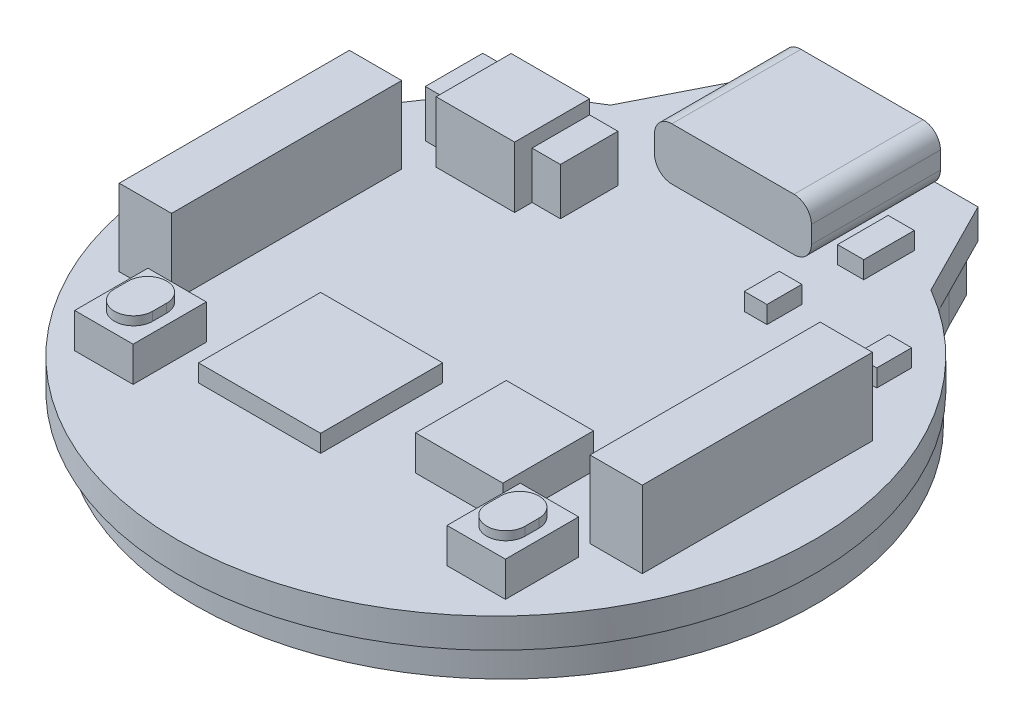
from build123d import *

# Parameters (mm, degrees)
BOSS_EXTRUDE1_DEPTH  = 1.7
BOSS_EXTRUDE2_DEPTH  = 2
BOSS_EXTRUDE3_START  = 1.7
SKETCH3_W            = 3
SKETCH3_H            = 13.2
BOSS_EXTRUDE3_DEPTH  = 4.4
BOSS_EXTRUDE4_START  = -21
BOSS_EXTRUDE4_DEPTH  = 7.4
CUT_EXTRUDE1_START   = -21
CUT_EXTRUDE1_DEPTH   = 6
BOSS_EXTRUDE5_START  = -15
SKETCH8_W            = 6
SKETCH8_H            = 0.65
BOSS_EXTRUDE5_DEPTH  = 5
FILLET1_R            = 0.5
BOSS_EXTRUDE6_START  = 1.7
SKETCH9_W            = 5
SKETCH9_H            = 5.2
BOSS_EXTRUDE6_DEPTH  = 2
BOSS_EXTRUDE7_START  = 1.7
SKETCH10_W           = 3.35
SKETCH10_H           = 4.2
BOSS_EXTRUDE7_DEPTH  = 2
BOSS_EXTRUDE8_START  = 3.7
BOSS_EXTRUDE8_DEPTH  = 0.5
BOSS_EXTRUDE9_START  = 1.7
SKETCH12_W           = 4.5
SKETCH12_H           = 4.3
BOSS_EXTRUDE9_DEPTH  = 3.5
BOSS_EXTRUDE10_START = 1.7
SKETCH13_W           = 7.75
SKETCH13_H           = 3.3
BOSS_EXTRUDE10_DEPTH = 2.7
BOSS_EXTRUDE11_START = 1.7
SKETCH14_W           = 7
SKETCH14_H           = 7
BOSS_EXTRUDE11_DEPTH = 1
BOSS_EXTRUDE12_START = 1.7
SKETCH15_W           = 1.3
SKETCH15_H           = 2
BOSS_EXTRUDE12_DEPTH = 1
BOSS_EXTRUDE13_START = 1.7
SKETCH16_W           = 1.5
SKETCH16_H           = 2.9
BOSS_EXTRUDE13_DEPTH = 1


with BuildPart() as part:
    # Sketch1 → Boss-Extrude1 (new body)
    with BuildSketch(Plane(origin=(0, 0, 0), x_dir=(1, 0, 0), z_dir=(0, 1, 0))):
        with BuildLine():
            Line((-6.405, 21.250170418), (6.405, 21.250170418))
            Line((6.405, 21.250170418), (9.185, 15.770170418))
            ThreePointArc((9.185, 15.770170418), (0, -18.25), (-9.185, 15.770170418))
            Line((-9.185, 15.770170418), (-6.405, 21.250170418))
        make_face()
    extrude(amount=BOSS_EXTRUDE1_DEPTH)

    # Sketch2 → Boss-Extrude2 (add)
    with BuildSketch(Plane(origin=(0, 0, 0), x_dir=(1, 0, 0), z_dir=(0, 1, 0))):
        with BuildLine():
            Line((-6.75, 20.250170418), (6.75, 20.250170418))
            Line((6.75, 20.250170418), (7.794367451, 18.191489254))
            ThreePointArc((7.794367451, 18.191489254), (9.048926778, 16.291420125), (10.700777057, 14.724393497))
            ThreePointArc((10.700777057, 14.724393497), (0, -17.3), (-10.700777057, 14.724393497))
            ThreePointArc((-10.700777057, 14.724393497), (-9.048926778, 16.291420125), (-7.794367451, 18.191489254))
            Line((-7.794367451, 18.191489254), (-6.75, 20.250170418))
        make_face()
    extrude(amount=-BOSS_EXTRUDE2_DEPTH)

    # Sketch3 → Boss-Extrude3 (add)
    with BuildSketch(Plane(origin=(0, 0, 0), x_dir=(1, 0, 0), z_dir=(0, 1, 0)).offset(BOSS_EXTRUDE3_START)):
        with Locations((-13.5, 0)):
            Rectangle(SKETCH3_W, SKETCH3_H)
        with Locations((13.5, 0)):
            Rectangle(SKETCH3_W, SKETCH3_H)
    extrude(amount=BOSS_EXTRUDE3_DEPTH)

    # Sketch4 → Boss-Extrude4 (add)
    with BuildSketch(Plane.XY.offset(BOSS_EXTRUDE4_START)):
        with BuildLine():
            Line((3.5, 1.7), (-3.5, 1.7))
            ThreePointArc((-3.5, 1.7), (-4.207106781, 1.992893219), (-4.5, 2.7))
            Line((-4.5, 2.7), (-4.5, 3.7))
            ThreePointArc((-4.5, 3.7), (-4.207106781, 4.407106781), (-3.5, 4.7))
            Line((-3.5, 4.7), (3.5, 4.7))
            ThreePointArc((3.5, 4.7), (4.207106781, 4.407106781), (4.5, 3.7))
            Line((4.5, 3.7), (4.5, 2.7))
            ThreePointArc((4.5, 2.7), (4.207106781, 1.992893219), (3.5, 1.7))
        make_face()
    extrude(amount=BOSS_EXTRUDE4_DEPTH)

    # Sketch7 → Cut-Extrude1 (cut)
    with BuildSketch(Plane.XY.offset(CUT_EXTRUDE1_START)):
        with BuildLine():
            Line((4.2, 2.7), (4.2, 3.7))
            ThreePointArc((4.2, 3.7), (3.994974747, 4.194974747), (3.5, 4.4))
            Line((3.5, 4.4), (-3.5, 4.4))
            ThreePointArc((-3.5, 4.4), (-3.994974747, 4.194974747), (-4.2, 3.7))
            Line((-4.2, 3.7), (-4.2, 2.7))
            ThreePointArc((-4.2, 2.7), (-3.994974747, 2.205025253), (-3.5, 2))
            Line((-3.5, 2), (3.5, 2))
            ThreePointArc((3.5, 2), (3.994974747, 2.205025253), (4.2, 2.7))
        make_face()
    extrude(amount=CUT_EXTRUDE1_DEPTH, mode=Mode.SUBTRACT)

    # Sketch8 → Boss-Extrude5 (add)
    with BuildSketch(Plane.XY.offset(BOSS_EXTRUDE5_START)):
        with Locations((0, 3.2)):
            Rectangle(SKETCH8_W, SKETCH8_H)
    extrude(amount=-BOSS_EXTRUDE5_DEPTH)

    # Fillet1
    fillet1_edges = [part.edges().sort_by_distance(p)[0] for p in [
        (-3, 3.2, -20),
        (3, 3.2, -20),
    ]]
    fillet(fillet1_edges, radius=FILLET1_R)

    # Sketch9 → Boss-Extrude6 (add)
    with BuildSketch(Plane(origin=(0, 0, 0), x_dir=(1, 0, 0), z_dir=(0, 1, 0)).offset(BOSS_EXTRUDE6_START)):
        with Locations((6, -5.5)):
            Rectangle(SKETCH9_W, SKETCH9_H)
    extrude(amount=BOSS_EXTRUDE6_DEPTH)

    # Sketch10 → Boss-Extrude7 (add)
    with BuildSketch(Plane(origin=(0, 0, 0), x_dir=(1, 0, 0), z_dir=(0, 1, 0)).offset(BOSS_EXTRUDE7_START)):
        with Locations((10.675, -9.7)):
            Rectangle(SKETCH10_W, SKETCH10_H)
        with Locations((-10.68, -9.7)):
            Rectangle(SKETCH10_W, SKETCH10_H)
    extrude(amount=BOSS_EXTRUDE7_DEPTH)

    # Sketch11 → Boss-Extrude8 (add)
    with BuildSketch(Plane(origin=(0, 0, 0), x_dir=(1, 0, 0), z_dir=(0, 1, 0)).offset(BOSS_EXTRUDE8_START)):
        with BuildLine():
            Line((-11.78, -10.1), (-11.78, -9.3))
            ThreePointArc((-11.78, -9.3), (-10.68, -8.2), (-9.58, -9.3))
            Line((-9.58, -9.3), (-9.58, -10.1))
            ThreePointArc((-9.58, -10.1), (-10.68, -11.2), (-11.78, -10.1))
        make_face()
        with BuildLine():
            Line((9.575, -10.1), (9.575, -9.3))
            ThreePointArc((9.575, -9.3), (10.675, -8.2), (11.775, -9.3))
            Line((11.775, -9.3), (11.775, -10.1))
            ThreePointArc((11.775, -10.1), (10.675, -11.2), (9.575, -10.1))
        make_face()
    extrude(amount=BOSS_EXTRUDE8_DEPTH)

    # Sketch12 → Boss-Extrude9 (add)
    with BuildSketch(Plane(origin=(0, 0, 0), x_dir=(1, 0, 0), z_dir=(0, 1, 0)).offset(BOSS_EXTRUDE9_START)):
        with Locations((-8.852751595, 9.830469474)):
            Rectangle(SKETCH12_W, SKETCH12_H)
    extrude(amount=BOSS_EXTRUDE9_DEPTH)

    # Sketch13 → Boss-Extrude10 (add)
    with BuildSketch(Plane(origin=(0, 0, 0), x_dir=(1, 0, 0), z_dir=(0, 1, 0)).offset(BOSS_EXTRUDE10_START)):
        with Locations((-8.852751595, 10.330469474)):
            Rectangle(SKETCH13_W, SKETCH13_H)
    extrude(amount=BOSS_EXTRUDE10_DEPTH)

    # Sketch14 → Boss-Extrude11 (add)
    with BuildSketch(Plane(origin=(0, 0, 0), x_dir=(1, 0, 0), z_dir=(0, 1, 0)).offset(BOSS_EXTRUDE11_START)):
        with Locations((-3.7, -6.35)):
            Rectangle(SKETCH14_W, SKETCH14_H)
    extrude(amount=BOSS_EXTRUDE11_DEPTH)

    # Sketch15 → Boss-Extrude12 (add)
    with BuildSketch(Plane(origin=(0, 0, 0), x_dir=(1, 0, 0), z_dir=(0, 1, 0)).offset(BOSS_EXTRUDE12_START)):
        with Locations((11.85, 10.35)):
            Rectangle(SKETCH15_W, SKETCH15_H)
        with Locations((5.55, 10.35)):
            Rectangle(SKETCH15_W, SKETCH15_H)
    extrude(amount=BOSS_EXTRUDE12_DEPTH)

    # Sketch16 → Boss-Extrude13 (add)
    with BuildSketch(Plane(origin=(0, 0, 0), x_dir=(1, 0, 0), z_dir=(0, 1, 0)).offset(BOSS_EXTRUDE13_START)):
        with Locations((6, 15.8)):
            Rectangle(SKETCH16_W, SKETCH16_H)
    extrude(amount=BOSS_EXTRUDE13_DEPTH)


with BuildPart() as part_1:
    # Body-Move/Copy2: moved
    add(part.part.moved(Location((0, -15.754739533, 0))))


solid = part_1.part
